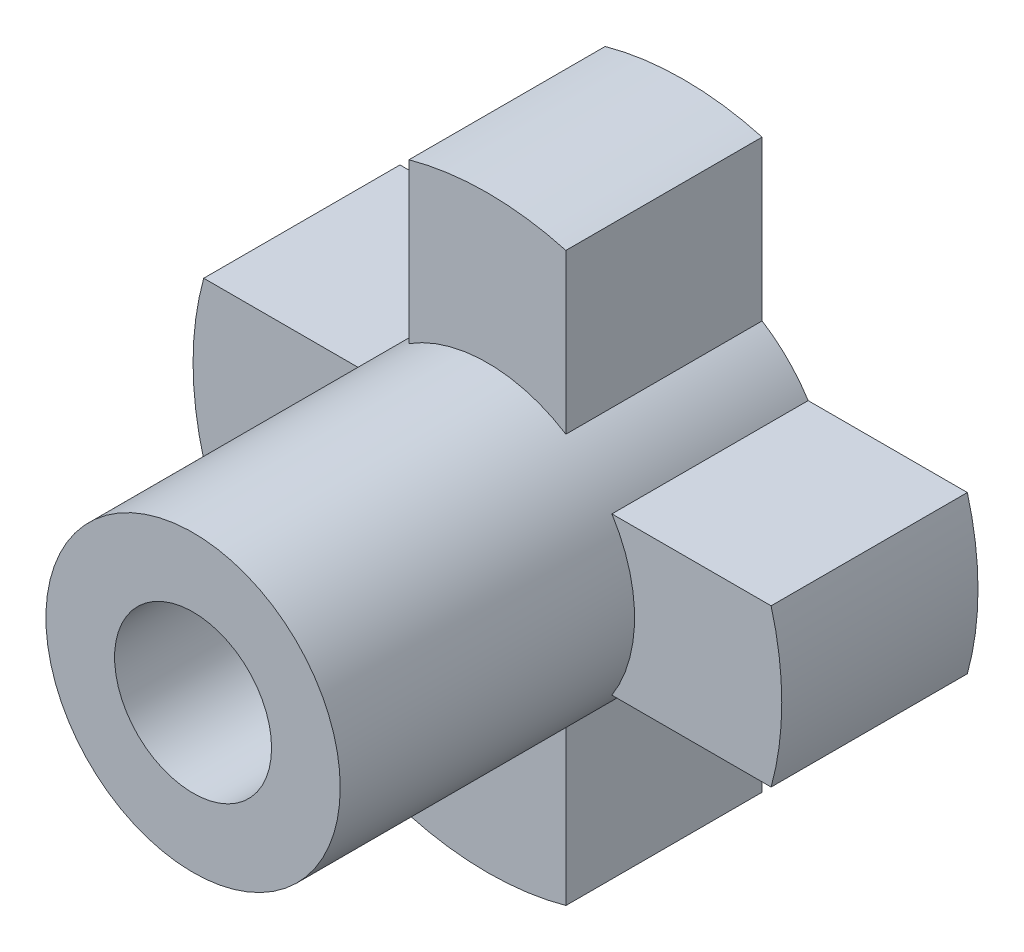
from build123d import *

# Parameters (mm, degrees)
ESBO_O1_R                = 15
RESSALTO_EXTRUS_O1_DEPTH = 10
ESBO_O2_R                = 7.5
RESSALTO_EXTRUS_O2_DEPTH = 15
ESBO_O3_R                = 4
CORTE_EXTRUS_O1_DEPTH    = 15
CORTE_EXTRUS_O2_DEPTH    = 20
ESBO_O5_R                = 1.5
CORTE_EXTRUS_O3_DEPTH    = 20


with BuildPart() as part:
    # Esboço1 → Ressalto-extrusão1 (new body)
    with BuildSketch(Plane.XY):
        Circle(ESBO_O1_R)
    extrude(amount=RESSALTO_EXTRUS_O1_DEPTH)

    # Esboço2 → Ressalto-extrusão2 (add)
    with BuildSketch(Plane.XY.offset(10)):
        Circle(ESBO_O2_R)
    extrude(amount=RESSALTO_EXTRUS_O2_DEPTH)

    # Esboço3 → Corte-extrusão1 (cut)
    with BuildSketch(Plane.XY.offset(25)):
        Circle(ESBO_O3_R)
    extrude(amount=-CORTE_EXTRUS_O1_DEPTH, mode=Mode.SUBTRACT)

    # Esboço4 → Corte-extrusão2 (cut)
    with BuildSketch(Plane(origin=(0, 0, 0), x_dir=(-1, 0, 0), z_dir=(0, 0, -1))):
        with BuildLine():
            Line((-4, 6.34428877), (-4, 14.456832295))
            ThreePointArc((-4, 14.456832295), (-10.606601718, 10.606601718), (-14.456832295, 4))
            Line((-14.456832295, 4), (-6.34428877, 4))
            ThreePointArc((-6.34428877, 4), (-5.303300859, 5.303300859), (-4, 6.34428877))
        make_face()
        with BuildLine():
            Line((4, -14.456832295), (4, -6.34428877))
            ThreePointArc((4, -6.34428877), (5.303300859, -5.303300859), (6.34428877, -4))
            Line((6.34428877, -4), (14.456832295, -4))
            ThreePointArc((14.456832295, -4), (10.606601718, -10.606601718), (4, -14.456832295))
        make_face()
        with BuildLine():
            Line((-4, -14.456832295), (-4, -6.34428877))
            ThreePointArc((-4, -6.34428877), (-5.303300859, -5.303300859), (-6.34428877, -4))
            Line((-6.34428877, -4), (-14.456832295, -4))
            ThreePointArc((-14.456832295, -4), (-10.606601718, -10.606601718), (-4, -14.456832295))
        make_face()
        with BuildLine():
            Line((14.456832295, 4), (6.34428877, 4))
            ThreePointArc((6.34428877, 4), (5.303300859, 5.303300859), (4, 6.34428877))
            Line((4, 6.34428877), (4, 14.456832295))
            ThreePointArc((4, 14.456832295), (10.606601718, 10.606601718), (14.456832295, 4))
        make_face()
    extrude(amount=-CORTE_EXTRUS_O2_DEPTH, mode=Mode.SUBTRACT)

    # Esboço5 → Corte-extrusão3 (cut)
    with BuildSketch(Plane(origin=(0, 0, 0), x_dir=(0, 0, -1), z_dir=(1, 0, 0))):
        with Locations((-13.004040431, 0)):
            Circle(ESBO_O5_R)
    extrude(amount=-CORTE_EXTRUS_O3_DEPTH, mode=Mode.SUBTRACT)


solid = part.part
